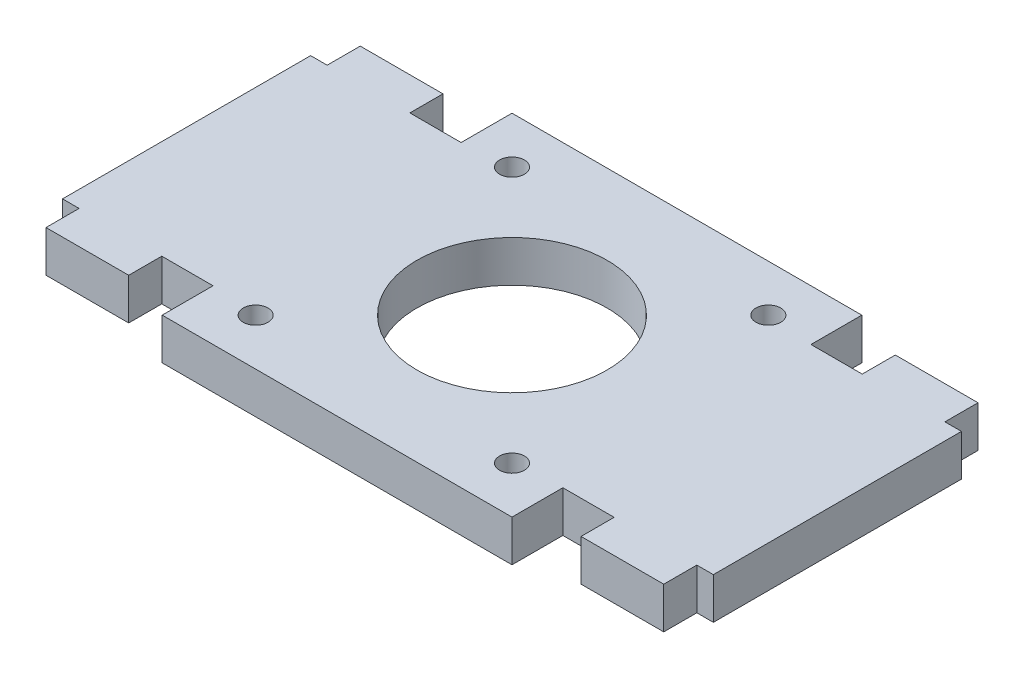
from build123d import *

# Parameters (mm, degrees)
SKETCH1_R           = 11.5
SKETCH1_R_2         = 1.5
BOSS_EXTRUDE1_DEPTH = 5


with BuildPart() as part:
    # Sketch1 → Boss-Extrude1 (new body)
    with BuildSketch(Plane(origin=(0, 0, 0), x_dir=(1, 0, 0), z_dir=(0, 1, 0))):
        Polygon((-39.35, -15), (-37.35, -15), (-37.35, -19), (-27.35, -19), (-27.35, -15), (-21.15, -15), (-21.15, -21.15), (21.15, -21.15), (21.15, -15), (27.35, -15), (27.35, -19), (37.35, -19), (37.35, -15), (39.35, -15), (39.35, 15), (37.35, 15), (37.35, 19), (27.35, 19), (27.35, 15), (21.15, 15), (21.15, 21.15), (-21.15, 21.15), (-21.15, 15), (-27.35, 15), (-27.35, 19), (-37.35, 19), (-37.35, 15), (-39.35, 15), align=None)
        Circle(SKETCH1_R, mode=Mode.SUBTRACT)
        with Locations((15.5, 15.5)):
            Circle(SKETCH1_R_2, mode=Mode.SUBTRACT)
        with Locations((15.5, -15.5)):
            Circle(SKETCH1_R_2, mode=Mode.SUBTRACT)
        with Locations((-15.5, -15.5)):
            Circle(SKETCH1_R_2, mode=Mode.SUBTRACT)
        with Locations((-15.5, 15.5)):
            Circle(SKETCH1_R_2, mode=Mode.SUBTRACT)
    extrude(amount=BOSS_EXTRUDE1_DEPTH)


solid = part.part
